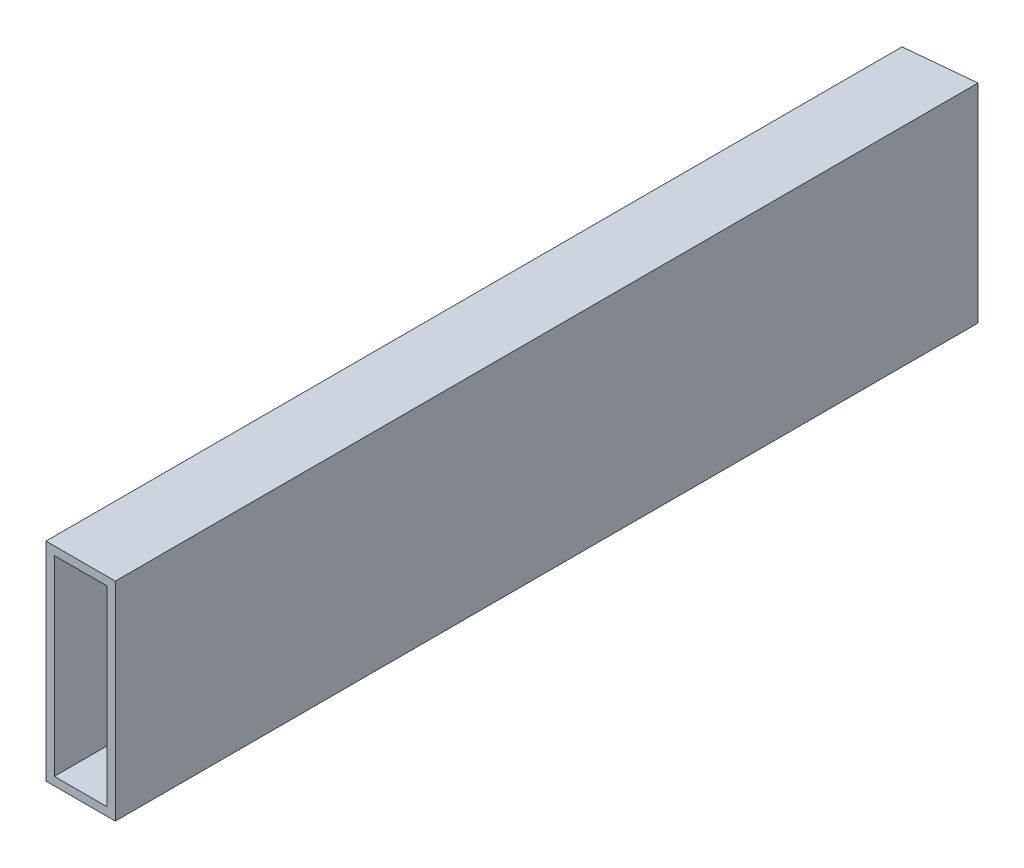
from build123d import *

# Parameters (mm, degrees)
SKETCH2_W               = 9.652
SKETCH2_H               = 3.048
SKETCH2_W_2             = 3.048
SKETCH2_H_2             = 35.052
BOSS_EXTRUDE1_DEPTH     = 315
SKETCH3_W               = 25.4
SKETCH3_H               = 76.2
SKETCH3_W_2             = 19.304
SKETCH3_H_2             = 70.104
BOSS_EXTRUDE2_DEPTH     = 50
CUT_EXTRUDE1_DEPTH      = 1
CUT_EXTRUDE1_DEPTH_BACK = 77.2


with BuildPart() as part:
    # Sketch2 → Boss-Extrude1 (new body)
    with BuildSketch(Plane.XY):
        Polygon((-12.7, 0), (-9.652, 0), (-9.652, 35.052), (-9.652, 38.1), (-12.7, 38.1), align=None)
        with Locations((-4.826, 36.576)):
            Rectangle(SKETCH2_W, SKETCH2_H)
        Polygon((0, 38.1), (0, 35.052), (9.652, 35.052), (9.652, 0), (12.7, 0), (12.7, 38.1), align=None)
        with Locations((11.176, -17.526)):
            Rectangle(SKETCH2_W_2, SKETCH2_H_2)
        Polygon((-9.652, -35.052), (-9.652, 0), (-12.7, 0), (-12.7, -38.1), (0, -38.1), (0, -35.052), align=None)
        Polygon((9.652, -35.052), (0, -35.052), (0, -38.1), (12.7, -38.1), (12.7, -35.052), align=None)
    extrude(amount=BOSS_EXTRUDE1_DEPTH)

    # Sketch3 → Boss-Extrude2 (add)
    with BuildSketch(Plane(origin=(0, 0, 0), x_dir=(-1, 0, 0), z_dir=(0, 0, -1))):
        Rectangle(SKETCH3_W, SKETCH3_H)
        Rectangle(SKETCH3_W_2, SKETCH3_H_2, mode=Mode.SUBTRACT)
    extrude(amount=BOSS_EXTRUDE2_DEPTH)

    # Sketch4 → Cut-Extrude1 (cut, two sides)
    with BuildSketch(Plane(origin=(0, 38.1, 0), x_dir=(1, 0, 0), z_dir=(0, 1, 0))) as cut_extrude1_sk:
        Polygon((-12.7, 46.179632344), (-70.94979307, -6.803292614), (-12.7, -1.217788135), align=None)
        Polygon((-77.560178635, 62.134722349), (-70.94979307, -6.803292614), (-12.7, 46.179632344), (-12.7, 50), (12.7, 50), (12.7, 1.217788135), (70.94979307, 6.803292614), (64.339407504, 75.741307577), align=None)
        Polygon((-12.7, 46.179632344), (-12.7, -1.217788135), (0, 0), (-9.501519639, 49.088910403), align=None)
        Polygon((-12.7, 50), (-12.7, 46.179632344), (-9.501519639, 49.088910403), (0, 0), (12.7, 1.217788135), (12.7, 50), align=None)
    extrude(amount=CUT_EXTRUDE1_DEPTH, mode=Mode.SUBTRACT)
    extrude(cut_extrude1_sk.sketch, amount=-CUT_EXTRUDE1_DEPTH_BACK, mode=Mode.SUBTRACT)


solid = part.part
